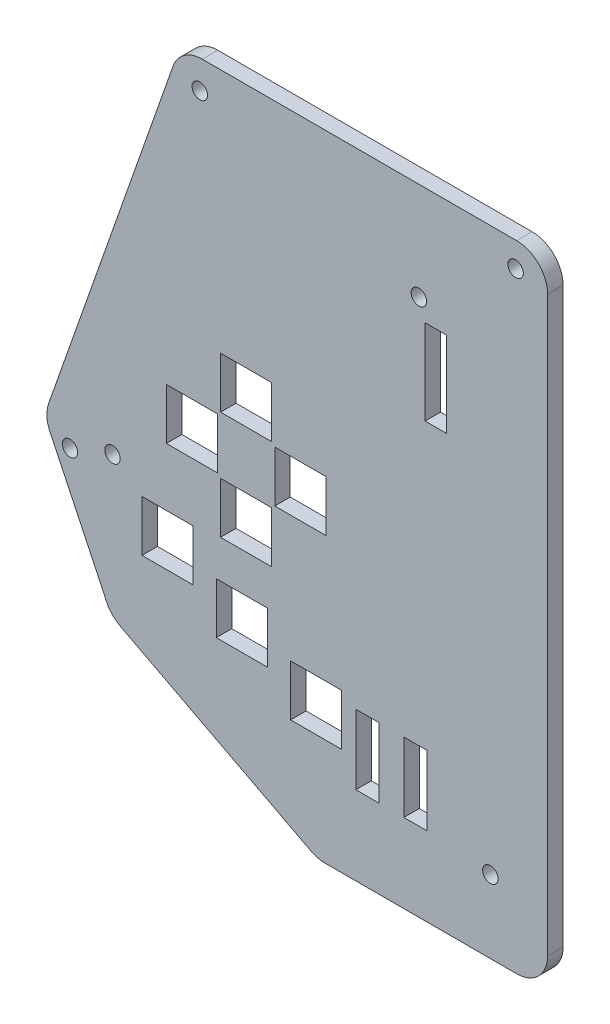
from build123d import *

# Parameters (mm, degrees)
BOSS_EXTRUDE1_DEPTH     = 2.54
SKETCH11_W              = 3.81
SKETCH11_H              = 11.43
SKETCH11_W_2            = 8.382
SKETCH11_H_2            = 8.382
CUT_EXTRUDE1_DEPTH      = 1
CUT_EXTRUDE1_DEPTH_BACK = 3.54
SKETCH12_R              = 1.27
CUT_EXTRUDE2_DEPTH      = 1
CUT_EXTRUDE2_DEPTH_BACK = 3.54
SKETCH13_R              = 1.27
CUT_EXTRUDE3_DEPTH      = 1
CUT_EXTRUDE3_DEPTH_BACK = 3.54
SKETCH14_W              = 3.556
SKETCH14_H              = 13.97
CUT_EXTRUDE4_DEPTH      = 1
CUT_EXTRUDE4_DEPTH_BACK = 3.54
SKETCH16_R              = 1.27
CUT_EXTRUDE5_DEPTH      = 1
CUT_EXTRUDE5_DEPTH_BACK = 3.54


with BuildPart() as part:
    # Sketch10 → Boss-Extrude1 (new body)
    with BuildSketch(Plane.XY):
        with BuildLine():
            Line((53.34, 1.27), (53.34, -92.71))
            ThreePointArc((53.34, -92.71), (51.852102448, -96.302102448), (48.26, -97.79))
            Line((48.26, -97.79), (16.846989059, -97.79))
            ThreePointArc((16.846989059, -97.79), (15.638688158, -97.644208035), (14.499741809, -97.215200367))
            Line((14.499741809, -97.215200367), (-16.7505185, -80.933552139))
            ThreePointArc((-16.7505185, -80.933552139), (-18.059258376, -79.955412607), (-18.989802686, -78.61241436))
            Line((-18.989802686, -78.61241436), (-28.309569459, -59.040904135))
            ThreePointArc((-28.309569459, -59.040904135), (-28.795802898, -57.127870198), (-28.51617555, -55.173917704))
            Line((-28.51617555, -55.173917704), (-8.107195629, 2.952923842))
            ThreePointArc((-8.107195629, 2.952923842), (-6.251501454, 5.414614163), (-3.314058103, 6.35))
            Line((-3.314058103, 6.35), (48.26, 6.35))
            ThreePointArc((48.26, 6.35), (51.852102448, 4.862102448), (53.34, 1.27))
        make_face()
    extrude(amount=BOSS_EXTRUDE1_DEPTH)

    # Sketch11 → Cut-Extrude1 (cut, two sides)
    with BuildSketch(Plane.XY.offset(2.54)) as cut_extrude1_sk:
        with Locations((31.65602, -79.121)):
            Rectangle(SKETCH11_W, SKETCH11_H)
        with Locations((23.78202, -79.121)):
            Rectangle(SKETCH11_W, SKETCH11_H)
        with Locations((3.878385852, -55.88)):
            Rectangle(SKETCH11_W_2, SKETCH11_H_2)
        with Locations((-5.011614148, -46.99)):
            Rectangle(SKETCH11_W_2, SKETCH11_H_2)
        with Locations((3.878385852, -38.1)):
            Rectangle(SKETCH11_W_2, SKETCH11_H_2)
        with Locations((12.768385852, -46.99)):
            Rectangle(SKETCH11_W_2, SKETCH11_H_2)
        with Locations((-9.017, -64.897)):
            Rectangle(SKETCH11_W_2, SKETCH11_H_2)
        with Locations((3.175, -70.485)):
            Rectangle(SKETCH11_W_2, SKETCH11_H_2)
        with Locations((15.367, -76.073)):
            Rectangle(SKETCH11_W_2, SKETCH11_H_2)
    extrude(amount=CUT_EXTRUDE1_DEPTH, mode=Mode.SUBTRACT)
    extrude(cut_extrude1_sk.sketch, amount=-CUT_EXTRUDE1_DEPTH_BACK, mode=Mode.SUBTRACT)

    # Sketch12 → Cut-Extrude2 (cut, two sides)
    with BuildSketch(Plane(origin=(0, 0, 0), x_dir=(-1, 0, 0), z_dir=(0, 0, -1))) as cut_extrude2_sk:
        with Locations((18.034, -57.15)):
            Circle(SKETCH12_R)
        with Locations((-43.942, -85.852)):
            Circle(SKETCH12_R)
    extrude(amount=CUT_EXTRUDE2_DEPTH, mode=Mode.SUBTRACT)
    extrude(cut_extrude2_sk.sketch, amount=-CUT_EXTRUDE2_DEPTH_BACK, mode=Mode.SUBTRACT)

    # Sketch13 → Cut-Extrude3 (cut, two sides)
    with BuildSketch(Plane(origin=(0, 0, 0), x_dir=(-1, 0, 0), z_dir=(0, 0, -1))) as cut_extrude3_sk:
        with Locations((25.012261453, -59.761967182)):
            Circle(SKETCH13_R)
        with Locations((-48.0822, 2.286)):
            Circle(SKETCH13_R)
        with Locations((3.718687848, 1.651)):
            Circle(SKETCH13_R)
    extrude(amount=CUT_EXTRUDE3_DEPTH, mode=Mode.SUBTRACT)
    extrude(cut_extrude3_sk.sketch, amount=-CUT_EXTRUDE3_DEPTH_BACK, mode=Mode.SUBTRACT)

    # Sketch14 → Cut-Extrude4 (cut, two sides)
    with BuildSketch(Plane(origin=(0, 0, 0), x_dir=(-1, 0, 0), z_dir=(0, 0, -1))) as cut_extrude4_sk:
        with Locations((-35.010498686, -19.798068862)):
            Rectangle(SKETCH14_W, SKETCH14_H)
    extrude(amount=CUT_EXTRUDE4_DEPTH, mode=Mode.SUBTRACT)
    extrude(cut_extrude4_sk.sketch, amount=-CUT_EXTRUDE4_DEPTH_BACK, mode=Mode.SUBTRACT)

    # Sketch16 → Cut-Extrude5 (cut, two sides)
    with BuildSketch(Plane(origin=(0, 0, 0), x_dir=(-1, 0, 0), z_dir=(0, 0, -1))) as cut_extrude5_sk:
        with Locations((-32.21898687, -9.676053038)):
            Circle(SKETCH16_R)
    extrude(amount=CUT_EXTRUDE5_DEPTH, mode=Mode.SUBTRACT)
    extrude(cut_extrude5_sk.sketch, amount=-CUT_EXTRUDE5_DEPTH_BACK, mode=Mode.SUBTRACT)


solid = part.part
